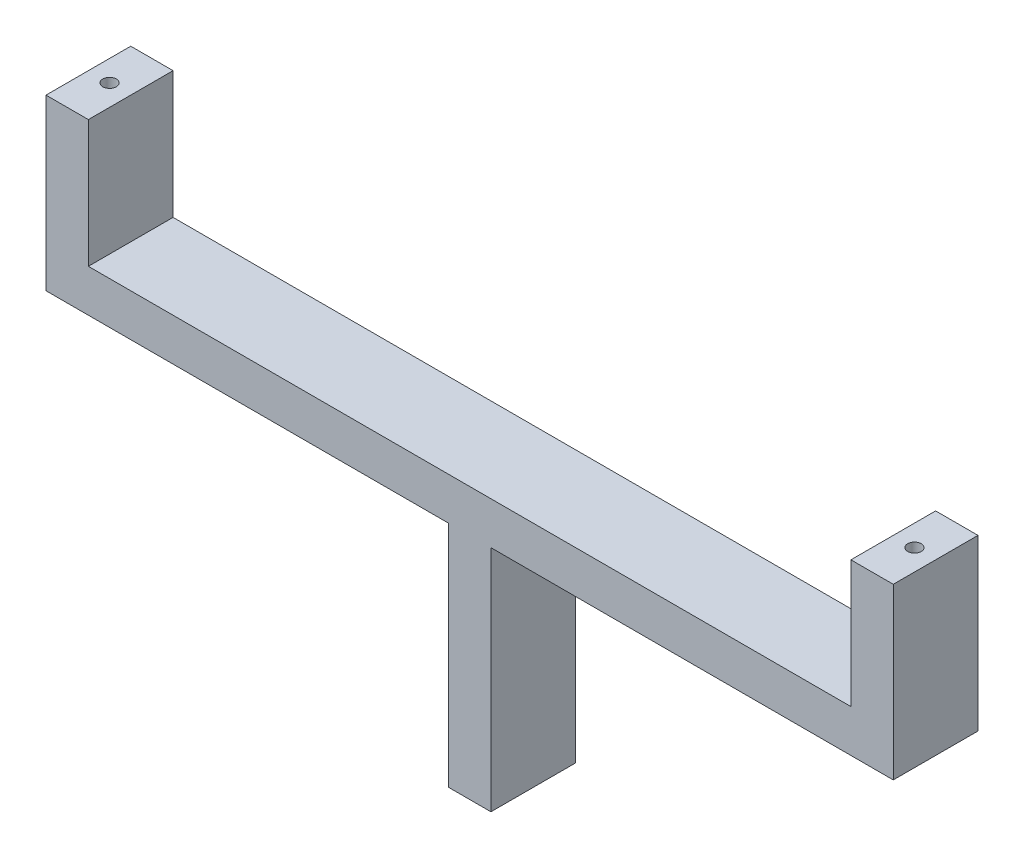
from build123d import *

# Parameters (mm, degrees)
CROQUIS1_W              = 100
CROQUIS1_H              = 10
SALIENTE_EXTRUIR1_DEPTH = 5
CROQUIS2_W              = 5
CROQUIS2_H              = 10
SALIENTE_EXTRUIR2_DEPTH = 15
CROQUIS3_R              = 0.8
CORTAR_EXTRUIR1_DEPTH   = 5
CROQUIS4_W              = 5.029184128
CROQUIS4_H              = 10
SALIENTE_EXTRUIR3_DEPTH = 27
CROQUIS5_R              = 0.8
CORTAR_EXTRUIR2_DEPTH   = 10


with BuildPart() as part:
    # Croquis1 → Saliente-Extruir1 (new body)
    with BuildSketch(Plane(origin=(0, 0, 0), x_dir=(1, 0, 0), z_dir=(0, 1, 0))):
        Rectangle(CROQUIS1_W, CROQUIS1_H)
    extrude(amount=SALIENTE_EXTRUIR1_DEPTH)

    # Croquis2 → Saliente-Extruir2 (add)
    with BuildSketch(Plane(origin=(0, 5, 0), x_dir=(1, 0, 0), z_dir=(0, 1, 0))):
        with Locations((-47.5, 0)):
            Rectangle(CROQUIS2_W, CROQUIS2_H)
        with Locations((47.5, 0)):
            Rectangle(CROQUIS2_W, CROQUIS2_H)
    extrude(amount=SALIENTE_EXTRUIR2_DEPTH)

    # Croquis3 → Cortar-Extruir1 (cut)
    with BuildSketch(Plane(origin=(0, 20, 0), x_dir=(1, 0, 0), z_dir=(0, 1, 0))):
        with Locations((-47.5, 0)):
            Circle(CROQUIS3_R)
        with Locations((47.5, 0)):
            Circle(CROQUIS3_R)
    extrude(amount=-CORTAR_EXTRUIR1_DEPTH, mode=Mode.SUBTRACT)

    # Croquis4 → Saliente-Extruir3 (add)
    with BuildSketch(Plane.XZ):
        Rectangle(CROQUIS4_W, CROQUIS4_H)
    extrude(amount=SALIENTE_EXTRUIR3_DEPTH)

    # Croquis5 → Cortar-Extruir2 (cut)
    with BuildSketch(Plane.XZ.offset(27)):
        Circle(CROQUIS5_R)
    extrude(amount=-CORTAR_EXTRUIR2_DEPTH, mode=Mode.SUBTRACT)


solid = part.part
